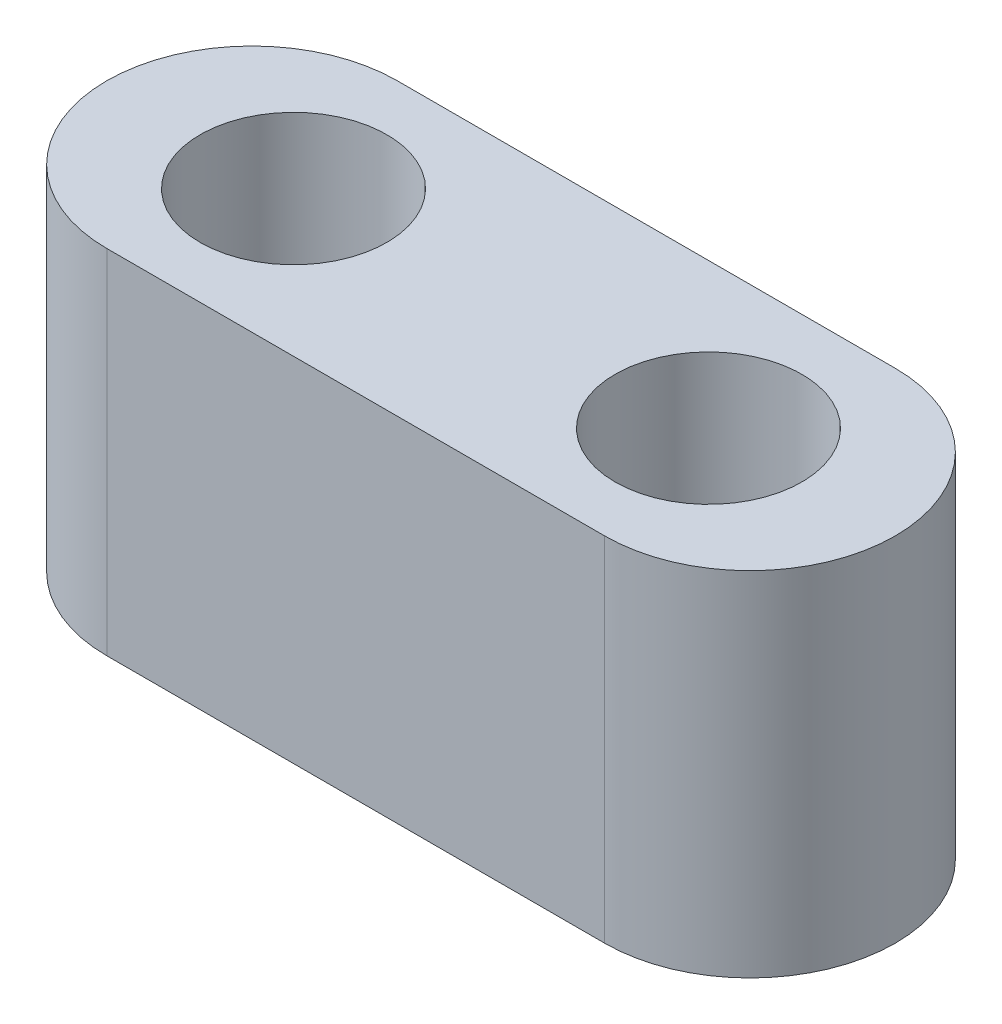
from build123d import *

# Parameters (mm, degrees)
SKETCH1_R           = 2.25
BOSS_EXTRUDE1_DEPTH = 8.5


with BuildPart() as part:
    # Sketch1 → Boss-Extrude1 (new body)
    with BuildSketch(Plane(origin=(0, 0, 0), x_dir=(1, 0, 0), z_dir=(0, 1, 0))):
        with BuildLine():
            Line((-6, -3.5), (6, -3.5))
            ThreePointArc((6, -3.5), (9.5, 0), (6, 3.5))
            Line((6, 3.5), (-6, 3.5))
            ThreePointArc((-6, 3.5), (-9.5, 0), (-6, -3.5))
        make_face()
        with Locations((5, 0)):
            Circle(SKETCH1_R, mode=Mode.SUBTRACT)
        with Locations((-5, 0)):
            Circle(SKETCH1_R, mode=Mode.SUBTRACT)
    extrude(amount=BOSS_EXTRUDE1_DEPTH)


solid = part.part
